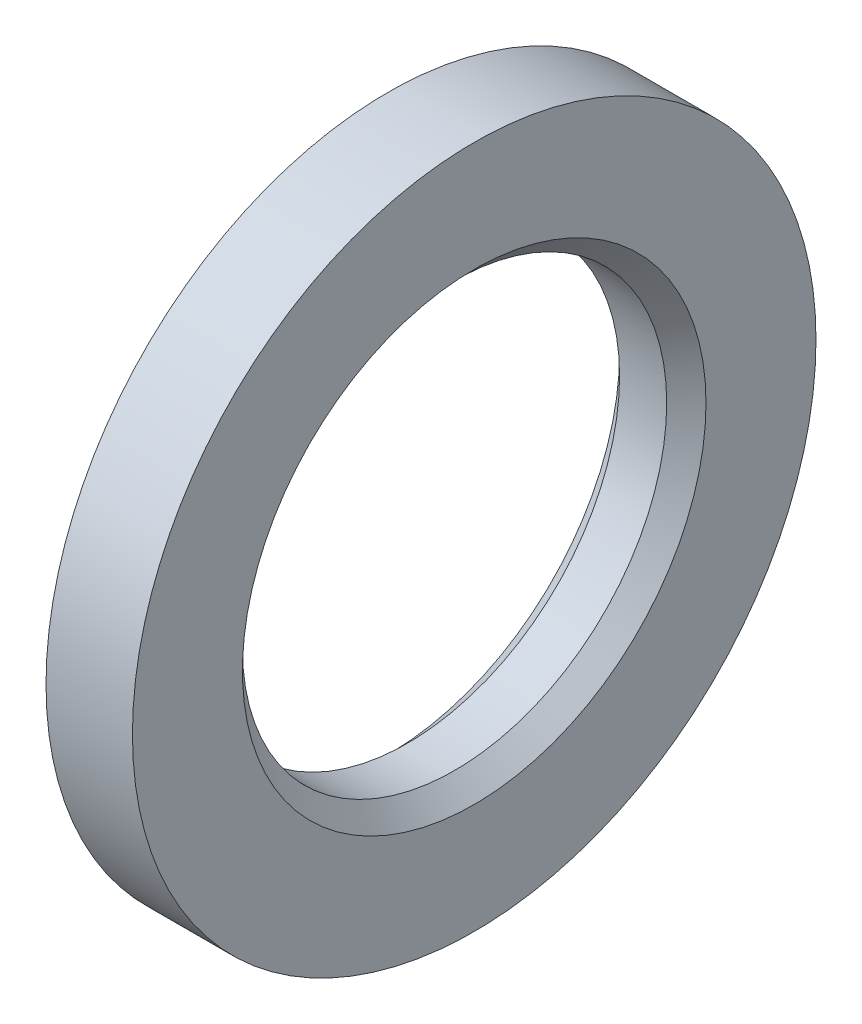
from build123d import *


with BuildPart() as part:
    # Sketch1 → Revolve1 (revolve)
    with BuildSketch(Plane.XY):
        Polygon((0, 0.7493), (0, 1.1049), (-0.2794, 1.1049), (-0.2794, 0.7493), (-0.2159, 0.6858), (-0.0635, 0.6858), align=None)
    revolve(axis=Axis((-0.2794, 0, 0), (1, 0, 0)))


solid = part.part
